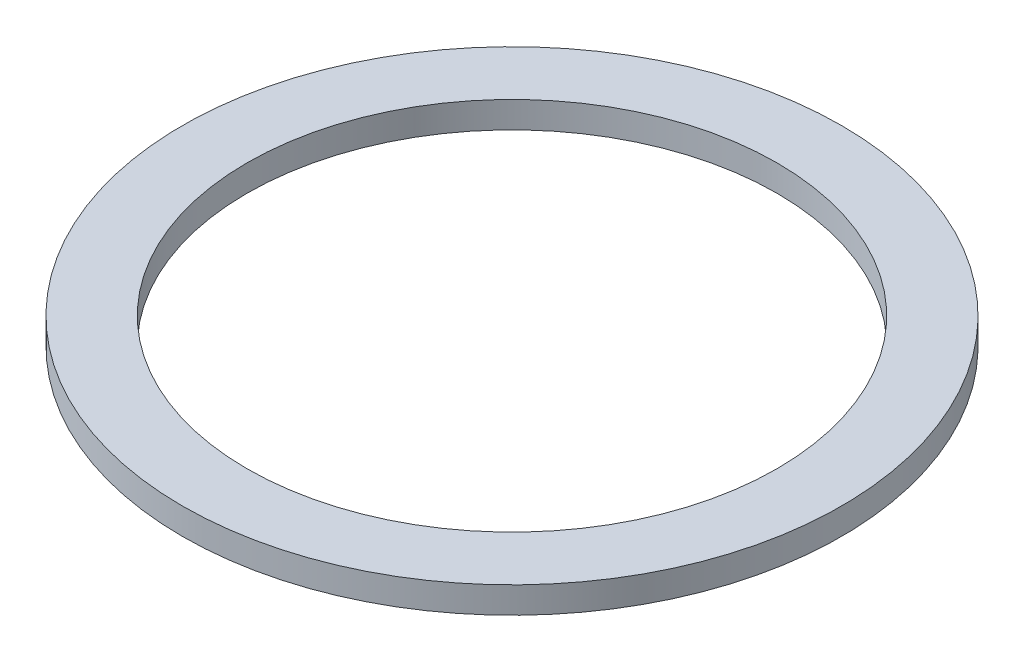
from build123d import *

# Parameters (mm, degrees)
SKETCH1_R           = 12.5
SKETCH1_R_2         = 10.05
BOSS_EXTRUDE1_DEPTH = 1


with BuildPart() as part:
    # Sketch1 → Boss-Extrude1 (new body)
    with BuildSketch(Plane(origin=(0, 0, 0), x_dir=(1, 0, 0), z_dir=(0, 1, 0))):
        Circle(SKETCH1_R)
        Circle(SKETCH1_R_2, mode=Mode.SUBTRACT)
    extrude(amount=BOSS_EXTRUDE1_DEPTH)


solid = part.part
